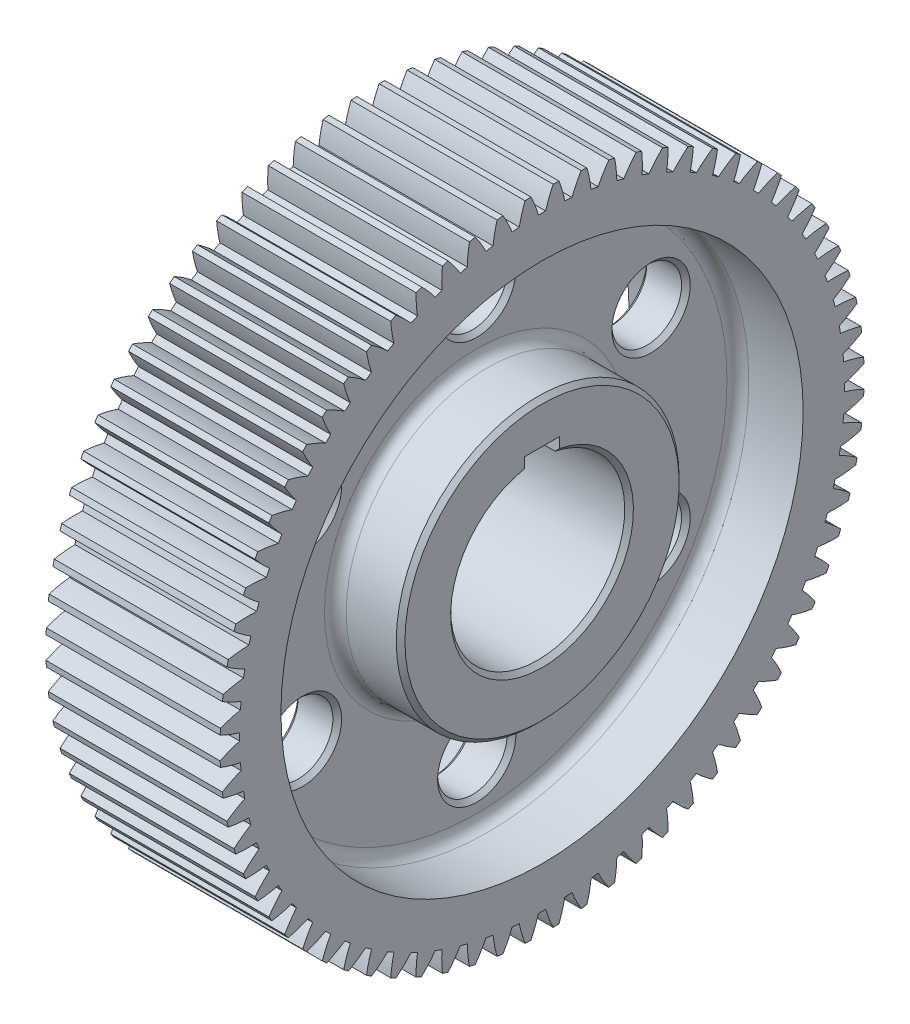
from build123d import *

# Parameters (mm, degrees)
BASPROSKE_W        = 80
BASPROSKE_H        = 148
TOOTHCUT_DEPTH     = 225.071417187
TEETHCUTS_COUNT    = 72
TEETHCUTS_ANGLE    = 355
BORSKE_R           = 40
BORE_DEPTH         = 80.0000508
SKETCH1_R          = 120
SKETCH1_R_2        = 65
CUT_EXTRUDE1_DEPTH = 30
CUT_EXTRUDE2_START = -80
SKETCH1_2_R        = 120
SKETCH1_2_R_2      = 65
CUT_EXTRUDE2_DEPTH = 30
SKETCH2_R          = 16
CUT_EXTRUDE3_DEPTH = 224.955235927
CIRPATTERN1_COUNT  = 6
SKETCH3_W          = 16
SKETCH3_H          = 12
CUT_EXTRUDE4_DEPTH = 224.955235927
FILLET1_R          = 5
CHAMFER1_SIZE      = 2


with BuildPart() as part:
    # BasProSke → Base-Revolve (revolve)
    with BuildSketch(Plane(origin=(0, 0, 0), x_dir=(1, 0, 0), z_dir=(0, 1, 0)), mode=Mode.PRIVATE) as base_revolve_sk:
        with Locations((40, 74)):
            Rectangle(BASPROSKE_W, BASPROSKE_H)
    revolve(base_revolve_sk.sketch.rotate(Axis((-10, 0, 0), (1, 0, 0)), 180), axis=Axis((-10, 0, 0), (1, 0, 0)))

    # TooCutSke → ToothCut (cut, through all)
    with BuildSketch(Plane(origin=(0, 0, 0), x_dir=(0, 0, -1), z_dir=(1, 0, 0))):
        with BuildLine():
            ThreePointArc((1.653765718, 138.989161664), (0, 138.999), (-1.653765718, 138.989161664))
            ThreePointArc((-1.653765718, 138.989161664), (-3.197131327, 143.53526187), (-5.113722447, 147.937043663))
            ThreePointArc((-5.113722447, 147.937043663), (0, 148.0254), (5.113722447, 147.937043663))
            ThreePointArc((5.113722447, 147.937043663), (3.197131327, 143.53526187), (1.653765718, 138.989161664))
        make_face()
    toothcut = extrude(amount=TOOTHCUT_DEPTH, mode=Mode.SUBTRACT)

    # TeethCuts: ToothCut ×72 about axis
    teethcuts_axis = Axis((-10, 0, 0), (1, 0, 0))
    for i in range(1, TEETHCUTS_COUNT):
        add(toothcut.rotate(teethcuts_axis, i * TEETHCUTS_ANGLE / (TEETHCUTS_COUNT - 1)), mode=Mode.SUBTRACT)

    # BorSke → Bore (cut, symmetric)
    with BuildSketch(Plane(origin=(0, 0, 0), x_dir=(0, 0, -1), z_dir=(1, 0, 0))):
        with Locations(Location((0, 0, 0), (0, 0, 180))):
            Circle(BORSKE_R)
    extrude(amount=BORE_DEPTH, both=True, mode=Mode.SUBTRACT)

    # Sketch1 → Cut-Extrude1 (cut)
    with BuildSketch(Plane(origin=(80, 0, 0), x_dir=(0, 0, -1), z_dir=(1, 0, 0))):
        Circle(SKETCH1_R)
        Circle(SKETCH1_R_2, mode=Mode.SUBTRACT)
    extrude(amount=-CUT_EXTRUDE1_DEPTH, mode=Mode.SUBTRACT)

    # Sketch1_2 → Cut-Extrude2 (cut)
    with BuildSketch(Plane(origin=(80, 0, 0), x_dir=(0, 0, -1), z_dir=(1, 0, 0)).offset(CUT_EXTRUDE2_START)):
        Circle(SKETCH1_2_R)
        Circle(SKETCH1_2_R_2, mode=Mode.SUBTRACT)
    extrude(amount=CUT_EXTRUDE2_DEPTH, mode=Mode.SUBTRACT)

    # Sketch2 → Cut-Extrude3 (cut, through all)
    with BuildSketch(Plane(origin=(80, 0, 0), x_dir=(0, 0, -1), z_dir=(1, 0, 0))):
        with Locations((0, 92.5)):
            Circle(SKETCH2_R)
    cut_extrude3 = extrude(amount=-CUT_EXTRUDE3_DEPTH, mode=Mode.SUBTRACT)

    # CirPattern1: Cut-Extrude3 ×6 about axis
    cirpattern1_axis = Axis((0, 0, 0), (1, 0, 0))
    for i in range(1, CIRPATTERN1_COUNT):
        add(cut_extrude3.rotate(cirpattern1_axis, i * 360 / CIRPATTERN1_COUNT), mode=Mode.SUBTRACT)

    # Sketch3 → Cut-Extrude4 (cut, through all)
    with BuildSketch(Plane(origin=(80, 0, 0), x_dir=(0, 0, -1), z_dir=(1, 0, 0))):
        with Locations((0, 40)):
            Rectangle(SKETCH3_W, SKETCH3_H)
    extrude(amount=-CUT_EXTRUDE4_DEPTH, mode=Mode.SUBTRACT)

    # Fillet1
    fillet1_edges = [part.edges().sort_by_distance(p)[0] for p in [
        (50, 0, 120),
        (50, 0, 65),
        (30, 0, 120),
        (30, 0, 65),
    ]]
    fillet(fillet1_edges, radius=FILLET1_R)

    # Chamfer1
    chamfer1_edges = [part.edges().sort_by_distance(p)[0] for p in [
        (80, 0, 65),
        (0, 0, 65),
        (50, 92.5, 16),
        (30, 92.5, 16),
        (50, 32.393593539, 88.10734985),
        (30, 32.393593539, 88.10734985),
        (50, -60.106406461, 72.10734985),
        (30, -60.106406461, 72.10734985),
        (50, -92.5, -16),
        (30, -92.5, -16),
        (50, -32.393593539, -88.10734985),
        (30, -32.393593539, -88.10734985),
        (50, 60.106406461, -72.10734985),
        (30, 60.106406461, -72.10734985),
        (0, -40, 0),
        (80, -40, 0),
    ]]
    chamfer(chamfer1_edges, length=CHAMFER1_SIZE)


solid = part.part
